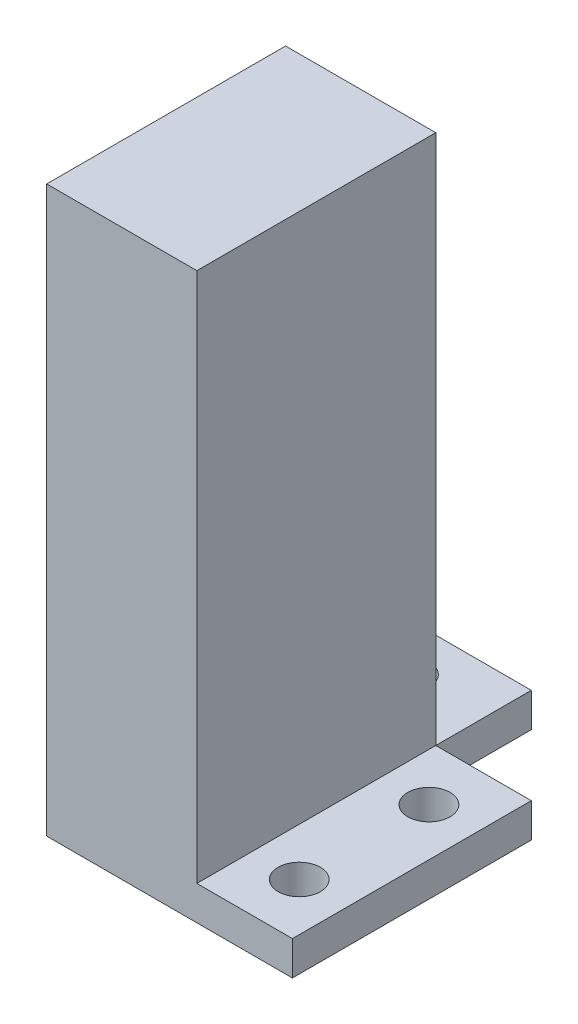
from build123d import *

# Parameters (mm, degrees)
SKETCH1_W           = 22
SKETCH1_H           = 82.75
SKETCH1_R           = 3.1
BOSS_EXTRUDE1_DEPTH = 30
SKETCH2_W           = 22
SKETCH2_H           = 82.75
BOSS_EXTRUDE2_DEPTH = 5
SKETCH3_W           = 22
SKETCH3_H           = 14
SKETCH3_R           = 3.1
SKETCH3_W_2         = 14
SKETCH3_H_2         = 35
BOSS_EXTRUDE3_DEPTH = 5


with BuildPart() as part:
    # Sketch1 → Boss-Extrude1 (new body)
    with BuildSketch(Plane.XY):
        with Locations((0, 7.844654309)):
            Rectangle(SKETCH1_W, SKETCH1_H)
        with Locations((0, 35.719654309)):
            Circle(SKETCH1_R, mode=Mode.SUBTRACT)
        with Locations((0, 7.719654309)):
            Circle(SKETCH1_R, mode=Mode.SUBTRACT)
    extrude(amount=BOSS_EXTRUDE1_DEPTH)

    # Sketch2 → Boss-Extrude2 (add)
    with BuildSketch(Plane.XY.offset(30)):
        with Locations((0, 7.844654309)):
            Rectangle(SKETCH2_W, SKETCH2_H)
    extrude(amount=BOSS_EXTRUDE2_DEPTH)

    # Sketch3 → Boss-Extrude3 (add)
    with BuildSketch(Plane.XZ.offset(33.530345691)):
        with Locations((0, -7)):
            Rectangle(SKETCH3_W, SKETCH3_H)
        with Locations((0, -7)):
            Circle(SKETCH3_R, mode=Mode.SUBTRACT)
        with Locations((18, 17.5)):
            Rectangle(SKETCH3_W_2, SKETCH3_H_2)
        with Locations((18, 27)):
            Circle(SKETCH3_R, mode=Mode.SUBTRACT)
        with Locations((18, 8)):
            Circle(SKETCH3_R, mode=Mode.SUBTRACT)
    extrude(amount=-BOSS_EXTRUDE3_DEPTH)


solid = part.part
